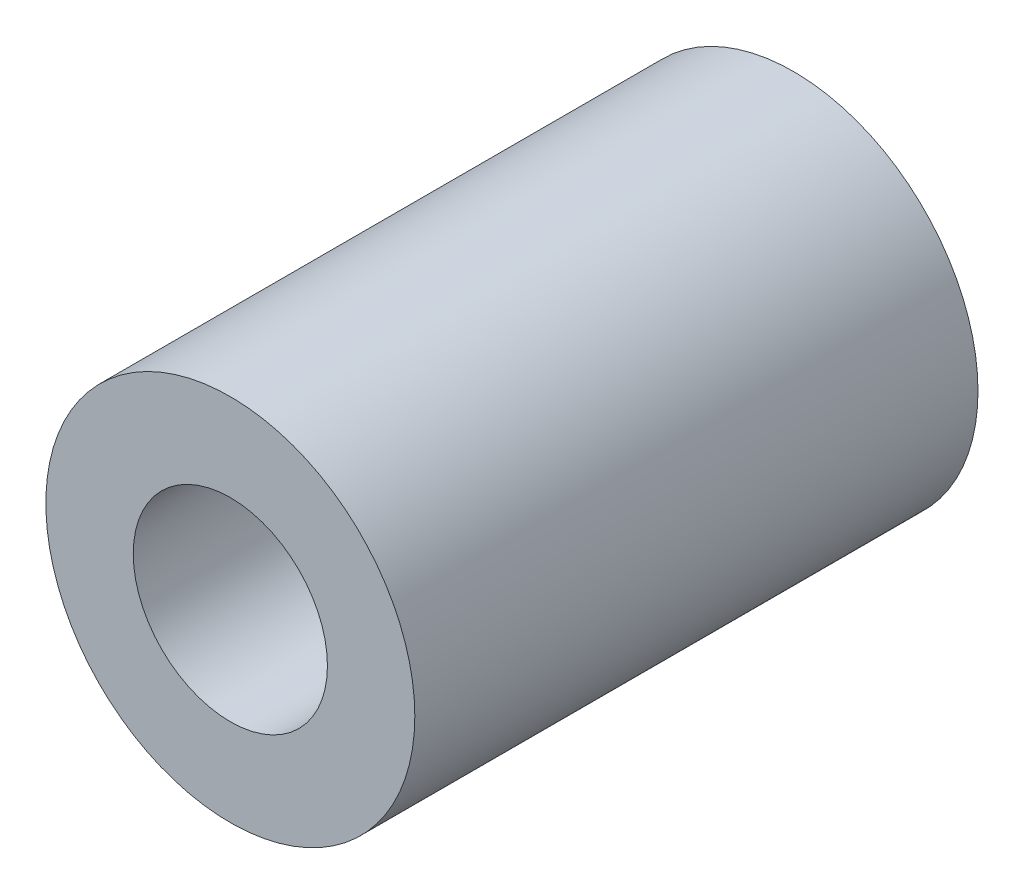
from build123d import *

# Parameters (mm, degrees)
SKETCH1_R           = 9.5
SKETCH1_R_2         = 5
BOSS_EXTRUDE1_DEPTH = 29


with BuildPart() as part:
    # Sketch1 → Boss-Extrude1 (new body)
    with BuildSketch(Plane.XY):
        Circle(SKETCH1_R)
        Circle(SKETCH1_R_2, mode=Mode.SUBTRACT)
    extrude(amount=BOSS_EXTRUDE1_DEPTH)


solid = part.part
